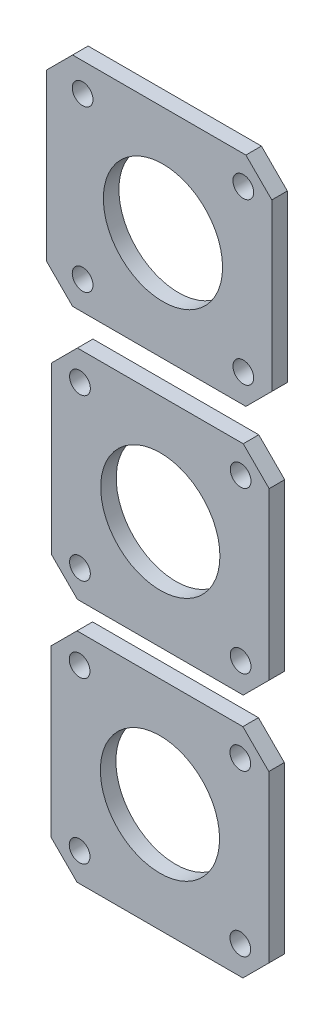
from build123d import *

# Parameters (mm, degrees)
SCHIZZO1_R                     = 11.5
SCHIZZO1_R_2                   = 2
ESTRUSIONE_ESTRUSIONE1_DEPTH   = 3
ESTRUSIONE_ESTRUSIONE1_2_DEPTH = 3
ESTRUSIONE_ESTRUSIONE1_3_DEPTH = 3


with BuildPart() as part:
    # Schizzo1 → Estrusione-Estrusione1 (new body)
    with BuildSketch(Plane.XY):
        Polygon((5, 0), (37, 0), (42, 5), (42, 37), (37, 42), (5, 42), (0, 37), (0, 5), align=None)
        with Locations((21, 21)):
            Circle(SCHIZZO1_R, mode=Mode.SUBTRACT)
        with Locations((5.5, 36.5)):
            Circle(SCHIZZO1_R_2, mode=Mode.SUBTRACT)
        with Locations((5.5, 5.5)):
            Circle(SCHIZZO1_R_2, mode=Mode.SUBTRACT)
        with Locations((36.5, 5.5)):
            Circle(SCHIZZO1_R_2, mode=Mode.SUBTRACT)
        with Locations((36.5, 36.5)):
            Circle(SCHIZZO1_R_2, mode=Mode.SUBTRACT)
    extrude(amount=-ESTRUSIONE_ESTRUSIONE1_DEPTH)


with BuildPart() as body_2:
    # Schizzo1 → Estrusione-Estrusione1 2 (new body)
    with BuildSketch(Plane.XY):
        Polygon((5.068599414, 47.294981331), (37.068599414, 47.294981331), (42.068599414, 52.294981331), (42.068599414, 84.294981331), (37.068599414, 89.294981331), (5.068599414, 89.294981331), (0.068599414, 84.294981331), (0.068599414, 52.294981331), align=None)
        with Locations((21.068599414, 68.294981331)):
            Circle(SCHIZZO1_R, mode=Mode.SUBTRACT)
        with Locations((5.568599414, 83.794981331)):
            Circle(SCHIZZO1_R_2, mode=Mode.SUBTRACT)
        with Locations((5.568599414, 52.794981331)):
            Circle(SCHIZZO1_R_2, mode=Mode.SUBTRACT)
        with Locations((36.568599414, 52.794981331)):
            Circle(SCHIZZO1_R_2, mode=Mode.SUBTRACT)
        with Locations((36.568599414, 83.794981331)):
            Circle(SCHIZZO1_R_2, mode=Mode.SUBTRACT)
    extrude(amount=-ESTRUSIONE_ESTRUSIONE1_2_DEPTH)


with BuildPart() as body_3:
    # Schizzo1 → Estrusione-Estrusione1 3 (new body)
    with BuildSketch(Plane.XY):
        Polygon((4.141702834, 95.789678478), (37.578861826, 95.789678478), (42.578861826, 100.789678478), (42.578861826, 132.789678478), (37.578861826, 137.789678478), (4.141702834, 137.789678478), (-0.858297166, 132.789678478), (-0.858297166, 100.789678478), align=None)
        with Locations((21.578861826, 116.789678478)):
            Circle(SCHIZZO1_R, mode=Mode.SUBTRACT)
        with Locations((6.078861826, 132.289678478)):
            Circle(SCHIZZO1_R_2, mode=Mode.SUBTRACT)
        with Locations((6.078861826, 101.289678478)):
            Circle(SCHIZZO1_R_2, mode=Mode.SUBTRACT)
        with Locations((37.078861826, 101.289678478)):
            Circle(SCHIZZO1_R_2, mode=Mode.SUBTRACT)
        with Locations((37.078861826, 132.289678478)):
            Circle(SCHIZZO1_R_2, mode=Mode.SUBTRACT)
    extrude(amount=-ESTRUSIONE_ESTRUSIONE1_3_DEPTH)


solid = Compound([part.part, body_2.part, body_3.part])
